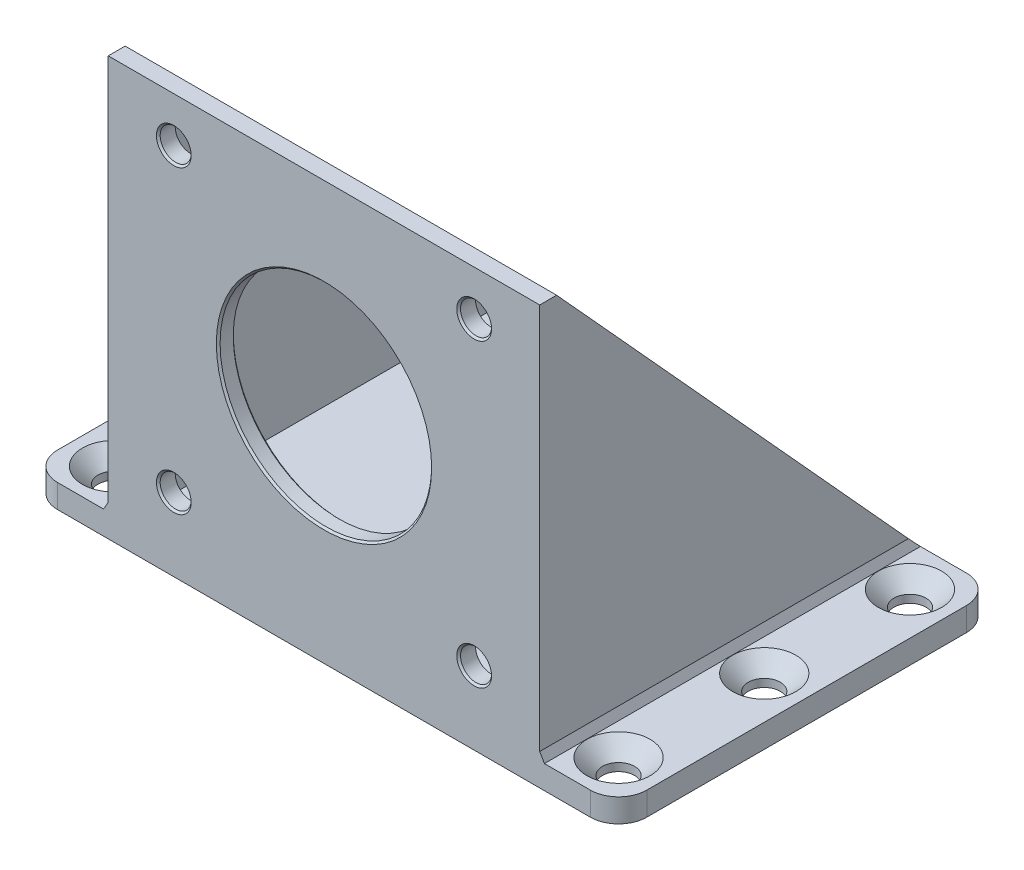
from build123d import *
from OCP.BRepFilletAPI import BRepFilletAPI_MakeChamfer

# Parameters (mm, degrees)
RESSALTO_EXTRUS_O1_DEPTH            = 1.25
ESBO_O2_W                           = 45.9
ESBO_O2_H                           = 40
ESBO_O2_W_2                         = 42.3
ESBO_O2_H_2                         = 36.4
RESSALTO_EXTRUS_O2_DEPTH            = 42
CORTE_EXTRUS_O1_DEPTH               = 58.030208881
CORTE_EXTRUS_O1_DEPTH_BACK          = 58.030208881
ESBO_O5_R                           = 11.25
CORTE_EXTRUS_O2_DEPTH               = 67.726641793
ESBO_O6_R                           = 1.65
CORTE_EXTRUS_O3_DEPTH               = 67.726641793
ESBO_O7_W                           = 42.3
ESBO_O7_H                           = 1.8
CORTE_EXTRUS_O4_DEPTH               = 57.08816475
ESCAREADO_PARA_SFHCS_M31_AT_2_COUNT = 2
ESCAREADO_PARA_SFHCS_M31_AT_2_PITCH = 15.5
ESCAREADO_PARA_SFHCS_M31_AT_3_COUNT = 2
ESCAREADO_PARA_SFHCS_M31_AT_3_PITCH = 15.5
ESCAREADO_PARA_SFHCS_M31_AT_4_COUNT = 2
ESCAREADO_PARA_SFHCS_M31_AT_4_PITCH = 55.863394992
ESCAREADO_PARA_SFHCS_M31_AT_5_COUNT = 2
ESCAREADO_PARA_SFHCS_M31_AT_5_PITCH = 53.67
ESCAREADO_PARA_SFHCS_M31_AT_6_COUNT = 2
ESCAREADO_PARA_SFHCS_M31_AT_6_PITCH = 55.863394992
CHANFRO1_SIZE                       = 0.5
CHANFRO1_SIZE2                      = 0.866025404
CHANFRO2_SIZE                       = 0.2


with BuildPart() as part:
    # Esboço1 → Ressalto-extrusão1 (new, symmetric)
    with BuildSketch(Plane(origin=(0, 0, 0), x_dir=(1, 0, 0), z_dir=(0, 1, 0))):
        with BuildLine():
            Line((-28.335, -20), (28.335, -20))
            ThreePointArc((28.335, -20), (30.456320344, -19.121320344), (31.335, -17))
            Line((31.335, -17), (31.335, 17))
            ThreePointArc((31.335, 17), (30.456320344, 19.121320344), (28.335, 20))
            Line((28.335, 20), (-28.335, 20))
            ThreePointArc((-28.335, 20), (-30.456320344, 19.121320344), (-31.335, 17))
            Line((-31.335, 17), (-31.335, -17))
            ThreePointArc((-31.335, -17), (-30.456320344, -19.121320344), (-28.335, -20))
        make_face()
    extrude(amount=RESSALTO_EXTRUS_O1_DEPTH, both=True)

    # Esboço2 → Ressalto-extrusão2 (add)
    with BuildSketch(Plane(origin=(0, 1.25, 0), x_dir=(1, 0, 0), z_dir=(0, 1, 0))):
        Rectangle(ESBO_O2_W, ESBO_O2_H)
        Rectangle(ESBO_O2_W_2, ESBO_O2_H_2, mode=Mode.SUBTRACT)
    extrude(amount=RESSALTO_EXTRUS_O2_DEPTH)

    # Esboço4 → Corte-extrusão1 (cut, two sides: drawn at the far end of the back side and taken through both)
    with BuildSketch(Plane(origin=(0, 0, 0), x_dir=(0, 0, -1), z_dir=(1, 0, 0)).offset(-CORTE_EXTRUS_O1_DEPTH_BACK)):
        Polygon((-18.2, 43.25), (20, 1.25), (20, 43.25), align=None)
    extrude(amount=CORTE_EXTRUS_O1_DEPTH + CORTE_EXTRUS_O1_DEPTH_BACK, mode=Mode.SUBTRACT)

    # Esboço5 → Corte-extrusão2 (cut, through all)
    with BuildSketch(Plane.XY.offset(20)):
        with Locations((0, 22.5)):
            Circle(ESBO_O5_R)
    extrude(amount=-CORTE_EXTRUS_O2_DEPTH, mode=Mode.SUBTRACT)

    # Esboço6 → Corte-extrusão3 (cut, through all)
    with BuildSketch(Plane.XY.offset(20)):
        with Locations((-15.975, 38.475)):
            Circle(ESBO_O6_R)
        with Locations((15.975, 38.475)):
            Circle(ESBO_O6_R)
        with Locations((15.975, 6.525)):
            Circle(ESBO_O6_R)
        with Locations((-15.975, 6.525)):
            Circle(ESBO_O6_R)
    extrude(amount=-CORTE_EXTRUS_O3_DEPTH, mode=Mode.SUBTRACT)

    # Esboço7 → Corte-extrusão4 (cut, through all)
    with BuildSketch(Plane(origin=(0, 1.25, 0), x_dir=(1, 0, 0), z_dir=(0, 1, 0))):
        with Locations((0, 19.1)):
            Rectangle(ESBO_O7_W, ESBO_O7_H)
    extrude(amount=CORTE_EXTRUS_O4_DEPTH, mode=Mode.SUBTRACT)

    # Esboço9 → Escareado para SFHCS M31 (revolve, cut)
    with BuildSketch(Plane(origin=(-26.835, 1.25, 0), x_dir=(0, 0, 1), z_dir=(1, 0, 0))):
        Polygon((0, 0), (0, 2.5), (1.7, 2.5), (1.7, 1.66), (3.36, 0), align=None)
    escareado_para_sfhcs_m31 = revolve(axis=Axis((-26.835, 7.6, 0), (0, -1, 0)), mode=Mode.SUBTRACT)

    # Escareado para SFHCS M31 at 2: Escareado para SFHCS M31 ×2
    with Locations(*[(0, 0, i * ESCAREADO_PARA_SFHCS_M31_AT_2_PITCH) for i in range(1, ESCAREADO_PARA_SFHCS_M31_AT_2_COUNT)]):
        add(escareado_para_sfhcs_m31, mode=Mode.SUBTRACT)

    # Escareado para SFHCS M31 at 3: Escareado para SFHCS M31 ×2
    with Locations(*[(0, 0, -i * ESCAREADO_PARA_SFHCS_M31_AT_3_PITCH) for i in range(1, ESCAREADO_PARA_SFHCS_M31_AT_3_COUNT)]):
        add(escareado_para_sfhcs_m31, mode=Mode.SUBTRACT)

    # Escareado para SFHCS M31 at 4: Escareado para SFHCS M31 ×2
    with Locations(*[Vector(0.9607364537719713, 0, -0.2774625495335487) * (i * ESCAREADO_PARA_SFHCS_M31_AT_4_PITCH) for i in range(1, ESCAREADO_PARA_SFHCS_M31_AT_4_COUNT)]):
        add(escareado_para_sfhcs_m31, mode=Mode.SUBTRACT)

    # Escareado para SFHCS M31 at 5: Escareado para SFHCS M31 ×2
    with Locations(*[(i * ESCAREADO_PARA_SFHCS_M31_AT_5_PITCH, 0, 0) for i in range(1, ESCAREADO_PARA_SFHCS_M31_AT_5_COUNT)]):
        add(escareado_para_sfhcs_m31, mode=Mode.SUBTRACT)

    # Escareado para SFHCS M31 at 6: Escareado para SFHCS M31 ×2
    with Locations(*[Vector(0.9607364537719713, 0, 0.2774625495335487) * (i * ESCAREADO_PARA_SFHCS_M31_AT_6_PITCH) for i in range(1, ESCAREADO_PARA_SFHCS_M31_AT_6_COUNT)]):
        add(escareado_para_sfhcs_m31, mode=Mode.SUBTRACT)

    # Chanfro1: one chamfer whose edges measure the first distance from different faces: ONE call of the kernel's chamfer builder (chamfer() names one face for all edges)
    chanfro1_edges_1 = [part.edges().sort_by_distance(p)[0] for p in [
        (-22.95, 1.25, 0),
    ]]
    chanfro1_side_1 = [part.faces().sort_by_distance(p)[0] for p in [
        (-30.167330013, 1.25, 18.832330013),
    ]]
    chanfro1_edges_2 = [part.edges().sort_by_distance(p)[0] for p in [
        (22.95, 1.25, 0),
    ]]
    chanfro1_side_2 = [part.faces().sort_by_distance(p)[0] for p in [
        (23.358694045, 1.25, 0),
    ]]
    chanfro1 = BRepFilletAPI_MakeChamfer(part.part.solid().wrapped)
    for e in chanfro1_edges_1:
        chanfro1.Add(CHANFRO1_SIZE, CHANFRO1_SIZE2, e.wrapped, chanfro1_side_1[0].wrapped)  # the first distance lies on this face
    for e in chanfro1_edges_2:
        chanfro1.Add(CHANFRO1_SIZE, CHANFRO1_SIZE2, e.wrapped, chanfro1_side_2[0].wrapped)  # the first distance lies on this face
    add(Compound.cast(chanfro1.Shape()), mode=Mode.REPLACE)

    # Chanfro2
    chanfro2_edges = [part.edges().sort_by_distance(p)[0] for p in [
        (-11.25, 22.5, 18.2),
        (-11.25, 22.5, 20),
        (-17.625, 6.525, 20),
        (14.325, 6.525, 20),
        (14.325, 38.475, 20),
        (-17.625, 38.475, 20),
    ]]
    chamfer(chanfro2_edges, length=CHANFRO2_SIZE)


solid = part.part
